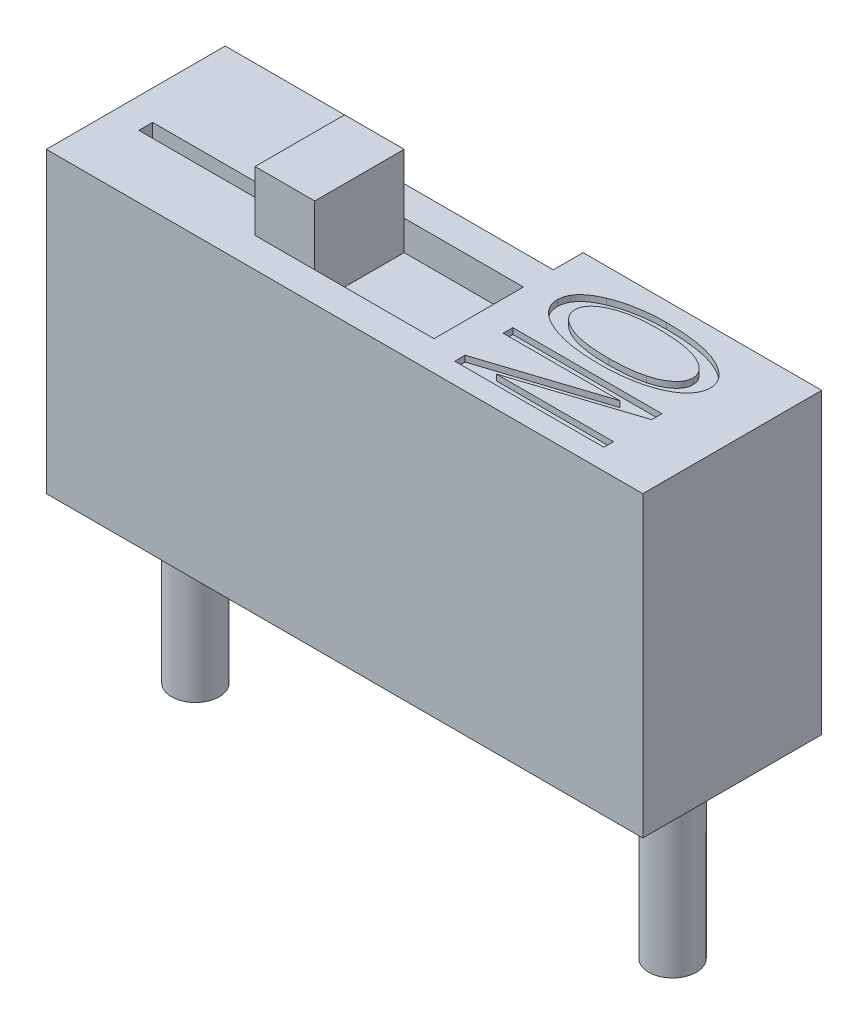
from build123d import *

# Parameters (mm, degrees)
ESBO_O1_W                = 10
ESBO_O1_H                = 3
RESSALTO_EXTRUS_O1_DEPTH = 5
ESBO_O4_W                = 1
ESBO_O4_H                = 1.5
RESSALTO_EXTRUS_O2_DEPTH = 1
ESBO_O8_W                = 2
ESBO_O8_H                = 1.5
CORTE_EXTRUS_O2_DEPTH    = 0.5
CORTE_EXTRUS_O5_DEPTH    = 0.1
CORTE_EXTRUS_O6_DEPTH    = 0.5
ESBO_O11_R               = 0.4
RESSALTO_EXTRUS_O4_DEPTH = 3
ESBO_O19_W               = 3
ESBO_O19_H               = 2
CORTE_EXTRUS_O9_DEPTH    = 0.5
ESBO_O21_W               = 2.995544047
ESBO_O21_H               = 1
CORTE_EXTRUS_O10_DEPTH   = 0.3


with BuildPart() as part:
    # Esboço1 → Ressalto-extrusão1 (new body)
    with BuildSketch(Plane(origin=(0, 0, 0), x_dir=(1, 0, 0), z_dir=(0, 1, 0))):
        with Locations((5, 1.5)):
            Rectangle(ESBO_O1_W, ESBO_O1_H)
    extrude(amount=RESSALTO_EXTRUS_O1_DEPTH)

    # Esboço4 → Ressalto-extrusão2 (add)
    with BuildSketch(Plane(origin=(0, 5, 0), x_dir=(1, 0, 0), z_dir=(0, 1, 0))):
        with Locations((3.5, 1.25)):
            Rectangle(ESBO_O4_W, ESBO_O4_H)
    extrude(amount=RESSALTO_EXTRUS_O2_DEPTH)

    # Esboço8 → Corte-extrusão2 (cut)
    with BuildSketch(Plane(origin=(0, 5, 0), x_dir=(1, 0, 0), z_dir=(0, 1, 0))):
        with Locations((5, 1.25)):
            Rectangle(ESBO_O8_W, ESBO_O8_H)
    extrude(amount=-CORTE_EXTRUS_O2_DEPTH, mode=Mode.SUBTRACT)

    # Esboço9 → Corte-extrusão5 (cut)
    with BuildSketch(Plane(origin=(0, 5, 0), x_dir=(1, 0, 0), z_dir=(0, 1, 0))):
        with BuildLine():
            add(Edge.make_bspline(
                [(7.717025162, 2.685064935), (7.768275073, 2.684653139), (7.867968532, 2.683852096), (8.012830606, 2.675522502), (8.148601104, 2.662599241), (8.275087284, 2.644432886), (8.392605867, 2.621489185), (8.500848932, 2.592511147), (8.600323781, 2.558959581), (8.689910066, 2.519182744), (8.770052693, 2.476635016), (8.839594359, 2.430662628), (8.899331263, 2.382896177), (8.947218272, 2.331040045), (8.986118217, 2.27759415), (9.012308422, 2.220411921), (9.029958288, 2.161052106), (9.031626399, 2.120222692), (9.032467532, 2.09963474)],
                knots=[0, 0, 0, 0, 0.000153734, 0.000299051, 0.000435142, 0.000562774, 0.000682263, 0.000794121, 0.000898722, 0.000996847, 0.001087864, 0.001170597, 0.00124666, 0.001316656, 0.001381822, 0.001444006, 0.001504562, 0.001566156, 0.001566156, 0.001566156, 0.001566156], degree=3))
            add(Edge.make_bspline(
                [(9.032467532, 2.09963474), (9.031952466, 2.086243406), (9.03092816, 2.059612265), (9.023519116, 2.020284156), (9.011816828, 1.98174038), (8.994996923, 1.944322939), (8.973326429, 1.907779642), (8.946647613, 1.872377676), (8.91588358, 1.837308554), (8.879929464, 1.803879089), (8.84003574, 1.771271209), (8.79508583, 1.741089795), (8.746201299, 1.712010826), (8.693008442, 1.684722634), (8.635338402, 1.659358364), (8.573479622, 1.635698049), (8.507410398, 1.613183974), (8.437075438, 1.593196089), (8.363020356, 1.57481891), (8.285320249, 1.559134103), (8.204039884, 1.546195816), (8.119518678, 1.534740096), (8.031299129, 1.526956469), (7.939792349, 1.520962638), (7.844740014, 1.516511464), (7.78027454, 1.516327433), (7.747463474, 1.516233766)],
                knots=[0, 0, 0, 0, 4.0157e-05, 7.986e-05, 0.000119657, 0.000160761, 0.00020261, 0.000246848, 0.000293569, 0.000342376, 0.000393954, 0.000447987, 0.000504626, 0.000564524, 0.000627211, 0.000693536, 0.000763161, 0.000836538, 0.000912823, 0.000992017, 0.001074251, 0.001159703, 0.001247841, 0.001339865, 0.001434818, 0.00153324, 0.00153324, 0.00153324, 0.00153324], degree=3))
            add(Edge.make_bspline(
                [(7.747463474, 1.516233766), (7.702642019, 1.51673791), (7.614970919, 1.517724018), (7.486687775, 1.524909023), (7.364657949, 1.536494006), (7.248954096, 1.552416836), (7.139735974, 1.573715014), (7.036976444, 1.599695769), (6.940209946, 1.629432703), (6.87929448, 1.654605061), (6.849533279, 1.666903409)],
                knots=[0, 0, 0, 0, 0.00013446, 0.000263004, 0.000385315, 0.000502115, 0.000613247, 0.000718938, 0.000820018, 0.000916578, 0.000916578, 0.000916578, 0.000916578], degree=3))
            add(Edge.make_bspline(
                [(6.849533279, 1.666903409), (6.819495721, 1.680737693), (6.762099909, 1.707172265), (6.684107261, 1.753561383), (6.617281662, 1.802485084), (6.562765507, 1.855474257), (6.520316361, 1.9119252), (6.489575578, 1.97162645), (6.471096623, 2.035136967), (6.468725659, 2.078717419), (6.467532468, 2.100649351)],
                knots=[0, 0, 0, 0, 9.9153e-05, 0.000189462, 0.000271747, 0.000347082, 0.000416684, 0.000482706, 0.000547582, 0.000613307, 0.000613307, 0.000613307, 0.000613307], degree=3))
            add(Edge.make_bspline(
                [(6.467532468, 2.100649351), (6.468673515, 2.122760058), (6.470934698, 2.166576254), (6.490149361, 2.23047144), (6.521930555, 2.290377771), (6.565195504, 2.347502443), (6.621476513, 2.400294414), (6.689828213, 2.449371296), (6.769790362, 2.49578785), (6.828783463, 2.521791334), (6.859679383, 2.535409903)],
                knots=[0, 0, 0, 0, 6.623e-05, 0.000131246, 0.000198184, 0.000268801, 0.000345229, 0.000428739, 0.000520798, 0.000622027, 0.000622027, 0.000622027, 0.000622027], degree=3))
            add(Edge.make_bspline(
                [(6.859679383, 2.535409903), (6.889983671, 2.547446904), (6.951310735, 2.571806293), (7.047289586, 2.602023308), (7.147652813, 2.628051521), (7.252801276, 2.648342721), (7.36221225, 2.665485653), (7.476356384, 2.676921818), (7.595195642, 2.68340278), (7.675925466, 2.6845042), (7.717025162, 2.685064935)],
                knots=[0, 0, 0, 0, 9.7794e-05, 0.000197907, 0.000301632, 0.000408684, 0.000519032, 0.000633771, 0.000752663, 0.000875964, 0.000875964, 0.000875964, 0.000875964], degree=3))
        make_face()
        with BuildLine():
            add(Edge.make_bspline(
                [(7.712966721, 2.522727273), (7.676265876, 2.522308225), (7.605018602, 2.52149473), (7.50124071, 2.516066621), (7.403787401, 2.506272361), (7.312351828, 2.493718156), (7.227668706, 2.475551712), (7.149030594, 2.455141256), (7.076719376, 2.430343071), (7.011040089, 2.401515886), (6.952378669, 2.370275717), (6.901011675, 2.337541762), (6.858096688, 2.302123084), (6.822086823, 2.265855819), (6.794084242, 2.227459146), (6.774410061, 2.1871143), (6.762168952, 2.14498675), (6.760550491, 2.116116802), (6.75974026, 2.101663961)],
                knots=[0, 0, 0, 0, 0.000110104, 0.000213745, 0.000311623, 0.000403886, 0.000490446, 0.000571292, 0.000647498, 0.000719509, 0.000786234, 0.00084674, 0.000901887, 0.00095283, 0.000999714, 0.00104373, 0.001086934, 0.001130246, 0.001130246, 0.001130246, 0.001130246], degree=3))
            add(Edge.make_bspline(
                [(6.75974026, 2.101663961), (6.760546361, 2.08687607), (6.762147128, 2.057510041), (6.774313031, 2.014588099), (6.794620069, 1.973819375), (6.82312444, 1.935125343), (6.858951297, 1.897980531), (6.902606815, 1.862790076), (6.954424216, 1.830037922), (7.013593655, 1.798559592), (7.080701403, 1.770420052), (7.15507718, 1.745439683), (7.237089191, 1.7250245), (7.326311037, 1.707753487), (7.423058943, 1.694892365), (7.527126513, 1.685211994), (7.638673744, 1.679804459), (7.715497711, 1.678990654), (7.755073052, 1.678571429)],
                knots=[0, 0, 0, 0, 4.4322e-05, 8.8015e-05, 0.00013271, 0.000180302, 0.00023161, 0.00028715, 0.000348081, 0.000415255, 0.000487996, 0.000566123, 0.000650406, 0.000741342, 0.000838628, 0.000943072, 0.001054818, 0.001173545, 0.001173545, 0.001173545, 0.001173545], degree=3))
            add(Edge.make_bspline(
                [(7.755073052, 1.678571429), (7.806337615, 1.67933264), (7.906298407, 1.680816928), (8.051928946, 1.692847075), (8.189578018, 1.711140794), (8.277380562, 1.731189916), (8.320211039, 1.740969968)],
                knots=[0, 0, 0, 0, 0.000153767, 0.00029983, 0.000438153, 0.000569888, 0.000569888, 0.000569888, 0.000569888], degree=3))
            add(Edge.make_bspline(
                [(8.320211039, 1.740969968), (8.350692489, 1.749465777), (8.409390915, 1.765826239), (8.490866203, 1.799714474), (8.563441842, 1.83845794), (8.625079395, 1.883949286), (8.675708543, 1.933016459), (8.713082539, 1.985414753), (8.736039938, 2.041202632), (8.738865882, 2.07965435), (8.74025974, 2.09862013)],
                knots=[0, 0, 0, 0, 9.485e-05, 0.000182653, 0.000264154, 0.000341064, 0.000411733, 0.000474779, 0.000533093, 0.00058985, 0.00058985, 0.00058985, 0.00058985], degree=3))
            add(Edge.make_bspline(
                [(8.74025974, 2.09862013), (8.739452698, 2.113743816), (8.737850374, 2.143770825), (8.725711477, 2.187701113), (8.705482151, 2.229237127), (8.67758473, 2.268647264), (8.642026485, 2.305993002), (8.598385597, 2.341015015), (8.546814492, 2.373728066), (8.487776446, 2.404835686), (8.420389396, 2.432702421), (8.344485848, 2.456804565), (8.260267259, 2.477516021), (8.167366142, 2.493969498), (8.065977549, 2.507157629), (7.955920014, 2.515874448), (7.837316624, 2.521580425), (7.755418511, 2.522335751), (7.712966721, 2.522727273)],
                knots=[0, 0, 0, 0, 4.5332e-05, 9.0004e-05, 0.000135611, 0.000183322, 0.00023428, 0.00028982, 0.000350751, 0.000417239, 0.000489784, 0.000569198, 0.000655941, 0.000749776, 0.000852091, 0.000962554, 0.001080888, 0.001208238, 0.001208238, 0.001208238, 0.001208238], degree=3))
        make_face(mode=Mode.SUBTRACT)
        Polygon((6.5, 1.321428571), (9, 1.321428571), (9, 1.148944805), (7.035714286, 0.50974026), (9, 0.50974026), (9, 0.347402597), (6.5, 0.347402597), (6.5, 0.520900974), (8.461241883, 1.159090909), (6.5, 1.159090909), align=None)
    extrude(amount=-CORTE_EXTRUS_O5_DEPTH, mode=Mode.SUBTRACT)

    # Esboço10 → Corte-extrusão6 (cut)
    with BuildSketch(Plane(origin=(0, 5, 0), x_dir=(1, 0, 0), z_dir=(0, 1, 0))):
        Polygon((2.5, 1.504407051), (2.5, 1.051282051), (0.5, 1.051282051), (0.5, 1.282051282), (2.294871795, 1.282051282), (2.294871795, 1.641025641), align=None)
    extrude(amount=-CORTE_EXTRUS_O6_DEPTH, mode=Mode.SUBTRACT)

    # Esboço11 → Ressalto-extrusão4 (add)
    with BuildSketch(Plane.XZ):
        with Locations((1, -1.5)):
            Circle(ESBO_O11_R)
        with Locations((9, -1.5)):
            Circle(ESBO_O11_R)
    extrude(amount=RESSALTO_EXTRUS_O4_DEPTH)

    # Esboço19 → Corte-extrusão9 (cut)
    with BuildSketch(Plane(origin=(0, 0, -3), x_dir=(-1, 0, 0), z_dir=(0, 0, -1))):
        with Locations((-4.5, 4)):
            Rectangle(ESBO_O19_W, ESBO_O19_H)
    extrude(amount=-CORTE_EXTRUS_O9_DEPTH, mode=Mode.SUBTRACT)

    # Esboço21 → Corte-extrusão10 (cut)
    with BuildSketch(Plane(origin=(0, 0, -3), x_dir=(-1, 0, 0), z_dir=(0, 0, -1))):
        with Locations((-4.502227977, 2.5)):
            Rectangle(ESBO_O21_W, ESBO_O21_H)
    extrude(amount=-CORTE_EXTRUS_O10_DEPTH, mode=Mode.SUBTRACT)


solid = part.part
